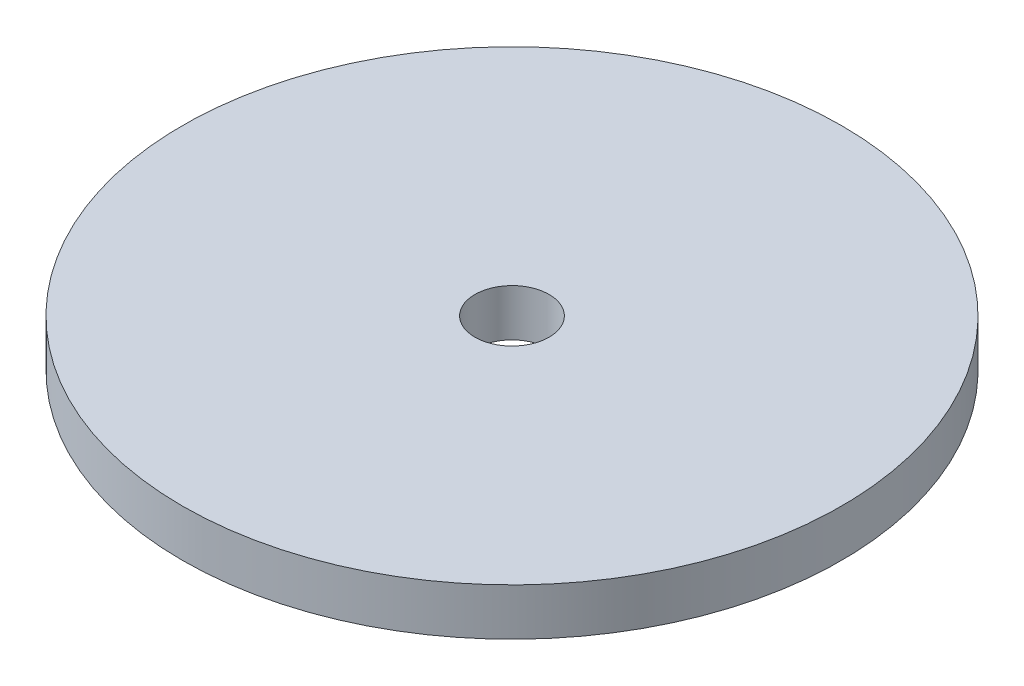
from build123d import *

# Parameters (mm, degrees)
SKETCH1_R           = 44.45
SKETCH1_R_2         = 5
BOSS_EXTRUDE1_DEPTH = 6.35


with BuildPart() as part:
    # Sketch1 → Boss-Extrude1 (new body)
    with BuildSketch(Plane(origin=(0, 0, 0), x_dir=(1, 0, 0), z_dir=(0, 1, 0))):
        Circle(SKETCH1_R)
        Circle(SKETCH1_R_2, mode=Mode.SUBTRACT)
    extrude(amount=BOSS_EXTRUDE1_DEPTH)


solid = part.part
